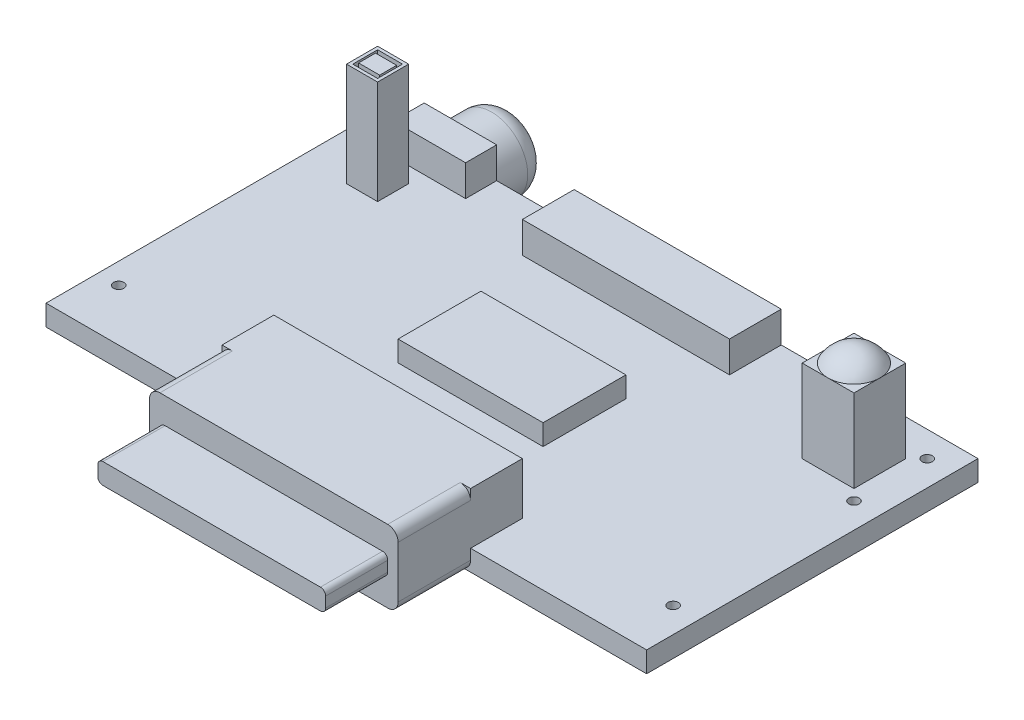
from build123d import *

# Parameters (mm, degrees)
SKETCH1_W           = 58
SKETCH1_H           = 32
EXTRUDE1_DEPTH      = 2
CUT_EXTRUDE1_REACH  = 4
SKETCH2_R           = 0.5
SKETCH3_W           = 5
SKETCH3_H           = 5
EXTRUDE2_DEPTH      = 8
SKETCH10_W          = 3
SKETCH10_H          = 3
FLASH_LED_BOX_DEPTH = 9
SKETCH12_W          = 3
SKETCH12_H          = 3
SKETCH12_W_2        = 2.4
SKETCH12_H_2        = 2.4
EXTRUDE4_DEPTH      = 1
SKETCH13_W          = 2.04
SKETCH13_H          = 1.64
EXTRUDE5_DEPTH      = 1
SKETCH14_W          = 24
SKETCH14_H          = 5
EXTRUDE6_DEPTH      = 5
EXTRUDE7_DEPTH      = 7
EXTRUDE8_DEPTH      = 6
SKETCH18_W          = 20
SKETCH18_H          = 5
TO_LCD_DEPTH        = 3
SKETCH19_W          = 14
SKETCH19_H          = 8
FLASH_MEMORY_DEPTH  = 2
SKETCH20_W          = 7
SKETCH20_H          = 3
EXTRUDE11_DEPTH     = 3
SKETCH21_R          = 3.5
EXTRUDE12_DEPTH     = 5
FILLET1_R           = 2


with BuildPart() as part:
    # Sketch1 → Extrude1 (new body)
    with BuildSketch(Plane(origin=(0, 0, 0), x_dir=(1, 0, 0), z_dir=(0, 1, 0))):
        with Locations((29, -16)):
            Rectangle(SKETCH1_W, SKETCH1_H)
    extrude(amount=EXTRUDE1_DEPTH)

    # Sketch2 → Cut-Extrude1 (cut, up to next)
    with BuildSketch(Plane(origin=(0, 2, 0), x_dir=(-1, 0, 0), z_dir=(0, 1, 0)), mode=Mode.PRIVATE) as cut_extrude1_sk1:
        with Locations((-55.557, 2.464)):
            Circle(SKETCH2_R)
    cut_extrude1_tool1 = extrude(cut_extrude1_sk1.sketch, amount=-CUT_EXTRUDE1_REACH, mode=Mode.PRIVATE) & part.part
    add(cut_extrude1_tool1.solids().sort_by_distance((55.557, 2, 2.464))[0], mode=Mode.SUBTRACT)
    # Sketch2 → Cut-Extrude1 (cut, up to next)
    with BuildSketch(Plane(origin=(0, 2, 0), x_dir=(-1, 0, 0), z_dir=(0, 1, 0)), mode=Mode.PRIVATE) as cut_extrude1_sk2:
        with Locations((-55.557, 9.535)):
            Circle(SKETCH2_R)
    cut_extrude1_tool2 = extrude(cut_extrude1_sk2.sketch, amount=-CUT_EXTRUDE1_REACH, mode=Mode.PRIVATE) & part.part
    add(cut_extrude1_tool2.solids().sort_by_distance((55.557, 2, 9.535))[0], mode=Mode.SUBTRACT)
    # Sketch2 → Cut-Extrude1 (cut, up to next)
    with BuildSketch(Plane(origin=(0, 2, 0), x_dir=(-1, 0, 0), z_dir=(0, 1, 0)), mode=Mode.PRIVATE) as cut_extrude1_sk3:
        with Locations((-55.557, 27)):
            Circle(SKETCH2_R)
    cut_extrude1_tool3 = extrude(cut_extrude1_sk3.sketch, amount=-CUT_EXTRUDE1_REACH, mode=Mode.PRIVATE) & part.part
    add(cut_extrude1_tool3.solids().sort_by_distance((55.557, 2, 27))[0], mode=Mode.SUBTRACT)
    # Sketch2 → Cut-Extrude1 (cut, up to next)
    with BuildSketch(Plane(origin=(0, 2, 0), x_dir=(-1, 0, 0), z_dir=(0, 1, 0)), mode=Mode.PRIVATE) as cut_extrude1_sk4:
        with Locations((-2.022, 27)):
            Circle(SKETCH2_R)
    cut_extrude1_tool4 = extrude(cut_extrude1_sk4.sketch, amount=-CUT_EXTRUDE1_REACH, mode=Mode.PRIVATE) & part.part
    add(cut_extrude1_tool4.solids().sort_by_distance((2.022, 2, 27))[0], mode=Mode.SUBTRACT)
    # Sketch2 → Cut-Extrude1 (cut, up to next)
    with BuildSketch(Plane(origin=(0, 2, 0), x_dir=(-1, 0, 0), z_dir=(0, 1, 0)), mode=Mode.PRIVATE) as cut_extrude1_sk5:
        with Locations((-2.022, 2.464)):
            Circle(SKETCH2_R)
    cut_extrude1_tool5 = extrude(cut_extrude1_sk5.sketch, amount=-CUT_EXTRUDE1_REACH, mode=Mode.PRIVATE) & part.part
    add(cut_extrude1_tool5.solids().sort_by_distance((2.022, 2, 2.464))[0], mode=Mode.SUBTRACT)

    # Sketch3 → Extrude2 (add)
    with BuildSketch(Plane(origin=(0, 2, 0), x_dir=(-1, 0, 0), z_dir=(0, 1, 0))):
        with Locations((-52.021432188, 5.9995)):
            Rectangle(SKETCH3_W, SKETCH3_H)
    extrude(amount=EXTRUDE2_DEPTH)

    # Sketch6 → Revolve1 (revolve)
    with BuildSketch(Plane(origin=(52.021432188, 0, 0), x_dir=(0, 0, -1), z_dir=(1, 0, 0))):
        with BuildLine():
            Line((-3.4995, 10), (-5.9995, 10))
            Line((-5.9995, 10), (-5.9995, 11.443375673))
            ThreePointArc((-5.9995, 11.443375673), (-4.556124327, 11.056624327), (-3.4995, 10))
        make_face()
    revolve(axis=Axis((52.021432188, 11.443375673, 5.9995), (0, -1, 0)))

    # Sketch10 → flash led box (add)
    with BuildSketch(Plane(origin=(0, 2, 0), x_dir=(-1, 0, 0), z_dir=(0, 1, 0))):
        with Locations((-6.022, 6)):
            Rectangle(SKETCH10_W, SKETCH10_H)
    extrude(amount=FLASH_LED_BOX_DEPTH)

    # Sketch12 → Extrude4 (add)
    with BuildSketch(Plane(origin=(0, 11, 0), x_dir=(-1, 0, 0), z_dir=(0, 1, 0))):
        with Locations((-6.022, 6)):
            Rectangle(SKETCH12_W, SKETCH12_H)
        with Locations((-6.022, 6)):
            Rectangle(SKETCH12_W_2, SKETCH12_H_2, mode=Mode.SUBTRACT)
    extrude(amount=EXTRUDE4_DEPTH)

    # Sketch13 → Extrude5 (add)
    with BuildSketch(Plane(origin=(0, 11, 0), x_dir=(-1, 0, 0), z_dir=(0, 1, 0))):
        with Locations((-6.022, 6)):
            Rectangle(SKETCH13_W, SKETCH13_H)
    extrude(amount=EXTRUDE5_DEPTH)

    # Sketch14 → Extrude6 (add)
    with BuildSketch(Plane(origin=(0, 2, 0), x_dir=(-1, 0, 0), z_dir=(0, 1, 0))):
        with Locations((-29, 29.5)):
            Rectangle(SKETCH14_W, SKETCH14_H)
    extrude(amount=EXTRUDE6_DEPTH)

    # Sketch16 → Extrude7 (add)
    with BuildSketch(Plane.XY.offset(32)):
        with BuildLine():
            Line((18, 7), (40, 7))
            ThreePointArc((40, 7), (40.707106781, 6.707106781), (41, 6))
            Line((41, 6), (41, 1))
            ThreePointArc((41, 1), (40.707106781, 0.292893219), (40, 0))
            Line((40, 0), (18, 0))
            ThreePointArc((18, 0), (17.292893219, 0.292893219), (17, 1))
            Line((17, 1), (17, 6))
            ThreePointArc((17, 6), (17.292893219, 6.707106781), (18, 7))
        make_face()
    extrude(amount=EXTRUDE7_DEPTH)

    # Sketch17 → Extrude8 (add)
    with BuildSketch(Plane.XY.offset(39)):
        with BuildLine():
            Line((18.5, 4.5), (39.5, 4.5))
            ThreePointArc((39.5, 4.5), (39.853553391, 4.353553391), (40, 4))
            Line((40, 4), (40, 3))
            ThreePointArc((40, 3), (39.853553391, 2.646446609), (39.5, 2.5))
            Line((39.5, 2.5), (18.5, 2.5))
            ThreePointArc((18.5, 2.5), (18.146446609, 2.646446609), (18, 3))
            Line((18, 3), (18, 4))
            ThreePointArc((18, 4), (18.146446609, 4.353553391), (18.5, 4.5))
        make_face()
    extrude(amount=EXTRUDE8_DEPTH)

    # Sketch18 → to lcd (add)
    with BuildSketch(Plane(origin=(0, 2, 0), x_dir=(-1, 0, 0), z_dir=(0, 1, 0))):
        with Locations((-29, 2.5)):
            Rectangle(SKETCH18_W, SKETCH18_H)
    extrude(amount=TO_LCD_DEPTH)

    # Sketch19 → flash memory (add)
    with BuildSketch(Plane(origin=(0, 2, 0), x_dir=(-1, 0, 0), z_dir=(0, 1, 0))):
        with Locations((-29, 16)):
            Rectangle(SKETCH19_W, SKETCH19_H)
    extrude(amount=FLASH_MEMORY_DEPTH)

    # Sketch20 → Extrude11 (add)
    with BuildSketch(Plane(origin=(0, 2, 0), x_dir=(-1, 0, 0), z_dir=(0, 1, 0))):
        with Locations((-8.02, 1.5)):
            Rectangle(SKETCH20_W, SKETCH20_H)
    extrude(amount=EXTRUDE11_DEPTH)

    # Sketch21 → Extrude12 (add)
    with BuildSketch(Plane(origin=(0, 0, 0), x_dir=(-1, 0, 0), z_dir=(0, 0, -1))):
        with Locations((-8.02, 1)):
            Circle(SKETCH21_R)
    extrude(amount=EXTRUDE12_DEPTH)

    # Fillet1
    fillet1_edges = [part.edges().sort_by_distance(p)[0] for p in [
        (11.52, 1, -5),
    ]]
    fillet(fillet1_edges, radius=FILLET1_R)


solid = part.part
